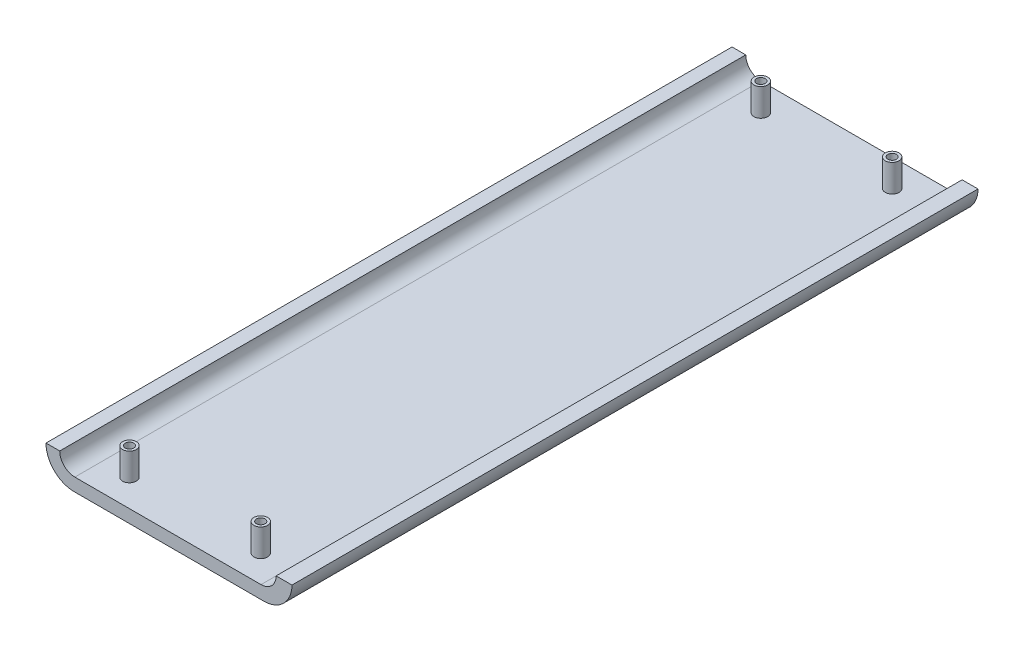
from build123d import *

# Parameters (mm, degrees)
BOSS_EXTRUDE1_DEPTH                = 127
SKETCH4_R                          = 1.27
BOSS_EXTRUDE2_DEPTH                = 5.08
F_1_16_0_0625_DIAMETER_HOLE1_D     = 1.5875
F_1_16_0_0625_DIAMETER_HOLE1_DEPTH = 7.478589674


with BuildPart() as part:
    # Sketch1 → Boss-Extrude1 (new body)
    with BuildSketch(Plane.XY):
        with BuildLine():
            Line((-33.131044693, 0), (2.017058644, 0))
            ThreePointArc((2.017058644, 0), (5.688774014, 1.520874304), (7.209648317, 5.192589674))
            Line((7.209648317, 5.192589674), (4.272091587, 5.192589674))
            ThreePointArc((4.272091587, 5.192589674), (3.453747934, 3.216933327), (1.478091587, 2.398589674))
            Line((1.478091587, 2.398589674), (-32.989634367, 2.398589674))
            ThreePointArc((-32.989634367, 2.398589674), (-34.965290713, 3.216933327), (-35.783634367, 5.192589674))
            Line((-35.783634367, 5.192589674), (-38.323634367, 5.192589674))
            ThreePointArc((-38.323634367, 5.192589674), (-36.802760063, 1.520874304), (-33.131044693, 0))
        make_face()
    extrude(amount=BOSS_EXTRUDE1_DEPTH)

    # Sketch4 → Boss-Extrude2 (add)
    with BuildSketch(Plane(origin=(0, 2.398589674, 0), x_dir=(1, 0, 0), z_dir=(0, 1, 0))):
        with Locations((-27.909634367, -5.08)):
            Circle(SKETCH4_R)
        with Locations((-3.601908413, -5.08)):
            Circle(SKETCH4_R)
        with Locations((-27.909634367, -121.964874012)):
            Circle(SKETCH4_R)
        with Locations((-3.601908413, -121.964874012)):
            Circle(SKETCH4_R)
    extrude(amount=BOSS_EXTRUDE2_DEPTH)

    # 1/16 (0.0625) Diameter Hole1
    with Locations(Plane(origin=(0, 7.478589674, 0), x_dir=(1, 0, 0), z_dir=(0, 1, 0))):
        with Locations((-27.909634367, -5.08), (-3.601908413, -5.08), (-27.909634367, -121.964874012), (-3.601908413, -121.964874012)):
            Hole(F_1_16_0_0625_DIAMETER_HOLE1_D / 2, depth=F_1_16_0_0625_DIAMETER_HOLE1_DEPTH)


solid = part.part
